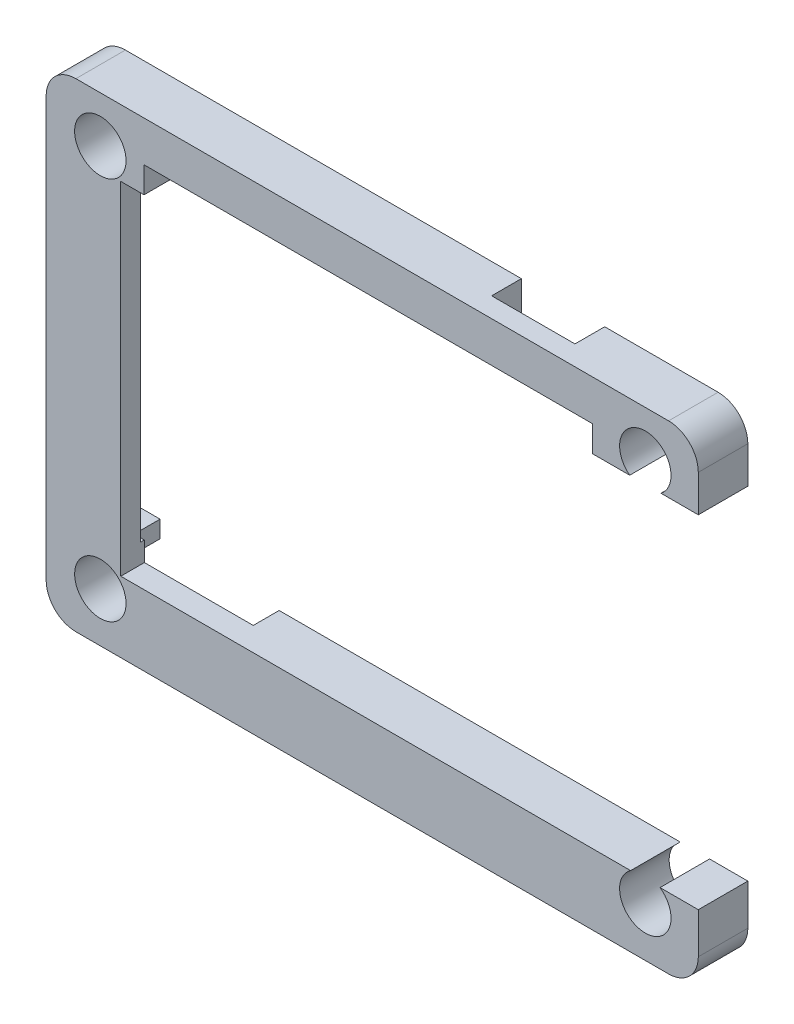
from build123d import *

# Parameters (mm, degrees)
SKETCH_1_R          = 2.594697184
SKETCH_1_W          = 50.755093491
SKETCH_1_H          = 34.509114599
EXTRUDE_1_DEPTH     = 5
SKETCH_2_W          = 12.017165499
SKETCH_2_H          = 2.614231611
CUT_EXTRUDE_1_DEPTH = 10
SKETCH_3_W          = 7.527857493
SKETCH_3_H          = 30.984988894
CUT_EXTRUDE_2_DEPTH = 3
SKETCH_4_W          = 11.818287361
SKETCH_4_H          = 34.509114599
CUT_EXTRUDE_3_DEPTH = 10
SKETCH_5_W          = 8.407446584
SKETCH_5_H          = 13.753485989
CUT_EXTRUDE_4_DEPTH = 3
SKETCH_6_W          = 45.235718037
SKETCH_6_H          = 4.020952714
CUT_EXTRUDE_5_DEPTH = 10


with BuildPart() as part:
    # 草图1 → 凸台-拉伸1 (new body)
    with BuildSketch(Plane.XY):
        with BuildLine():
            Line((-33.053422138, 25.444897132), (26.761429335, 25.444897132))
            ThreePointArc((26.761429335, 25.444897132), (28.882749679, 24.566217475), (29.761429335, 22.444897132))
            Line((29.761429335, 22.444897132), (29.761429335, -19.896984924))
            ThreePointArc((29.761429335, -19.896984924), (28.882749679, -22.018305267), (26.761429335, -22.896984924))
            Line((26.761429335, -22.896984924), (-33.053422138, -22.896984924))
            ThreePointArc((-33.053422138, -22.896984924), (-35.174742482, -22.018305267), (-36.053422138, -19.896984924))
            Line((-36.053422138, -19.896984924), (-36.053422138, 22.444897132))
            ThreePointArc((-36.053422138, 22.444897132), (-35.174742482, 24.566217475), (-33.053422138, 25.444897132))
        make_face()
        with Locations((-30.585365854, 20.792682927)):
            Circle(SKETCH_1_R, mode=Mode.SUBTRACT)
        with Locations((24.414634146, 20.792682927)):
            Circle(SKETCH_1_R, mode=Mode.SUBTRACT)
        with Locations((-30.585365854, -17.907317073)):
            Circle(SKETCH_1_R, mode=Mode.SUBTRACT)
        with Locations((24.414634146, -17.907317073)):
            Circle(SKETCH_1_R, mode=Mode.SUBTRACT)
        with Locations((-3.1480179, 1.476070041)):
            Rectangle(SKETCH_1_W, SKETCH_1_H, mode=Mode.SUBTRACT)
    extrude(amount=EXTRUDE_1_DEPTH)

    # 草图2 → 切除-拉伸1 (cut)
    with BuildSketch(Plane.XZ.offset(22.896984924)):
        with Locations((-23.547762162, 1.307115806)):
            Rectangle(SKETCH_2_W, SKETCH_2_H)
    extrude(amount=-CUT_EXTRUDE_1_DEPTH, mode=Mode.SUBTRACT)

    # 草图3 → 切除-拉伸2 (cut)
    with BuildSketch(Plane(origin=(0, 0, 0), x_dir=(-1, 0, 0), z_dir=(0, 0, -1))):
        with Locations((32.289493392, 1.687877711)):
            Rectangle(SKETCH_3_W, SKETCH_3_H)
    extrude(amount=-CUT_EXTRUDE_2_DEPTH, mode=Mode.SUBTRACT)

    # 草图4 → 切除-拉伸3 (cut)
    with BuildSketch(Plane.XY.offset(5)):
        with Locations((28.138672527, 1.476070041)):
            Rectangle(SKETCH_4_W, SKETCH_4_H)
    extrude(amount=-CUT_EXTRUDE_3_DEPTH, mode=Mode.SUBTRACT)

    # 草图5 → 切除-拉伸4 (cut)
    with BuildSketch(Plane(origin=(0, 0, 0), x_dir=(-1, 0, 0), z_dir=(0, 0, -1))):
        with Locations((-11.110108677, 20.556252076)):
            Rectangle(SKETCH_5_W, SKETCH_5_H)
    extrude(amount=-CUT_EXTRUDE_4_DEPTH, mode=Mode.SUBTRACT)

    # 草图6 → 切除-拉伸5 (cut)
    with BuildSketch(Plane(origin=(0, 0, 0), x_dir=(-1, 0, 0), z_dir=(0, 0, -1))):
        with Locations((3.557230201, 19.345396997)):
            Rectangle(SKETCH_6_W, SKETCH_6_H)
    extrude(amount=-CUT_EXTRUDE_5_DEPTH, mode=Mode.SUBTRACT)


solid = part.part
